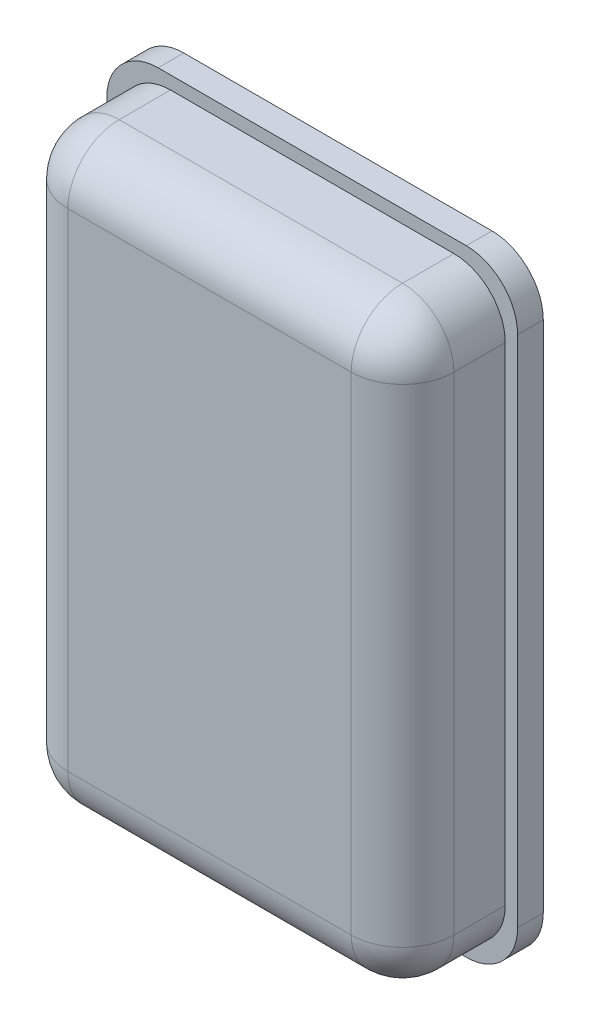
from build123d import *

# Parameters (mm, degrees)
CROQUIS1_W              = 80
CROQUIS1_H              = 120
SALIENTE_EXTRUIR1_DEPTH = 5
REDONDEO2_R             = 10
CROQUIS2_W              = 75.177590538
CROQUIS2_H              = 114.928834806
SALIENTE_EXTRUIR2_DEPTH = 20
REDONDEO1_R             = 10


with BuildPart() as part:
    # Croquis1 → Saliente-Extruir1 (new body)
    with BuildSketch(Plane.XY):
        Rectangle(CROQUIS1_W, CROQUIS1_H)
    extrude(amount=SALIENTE_EXTRUIR1_DEPTH)

    # Redondeo2
    redondeo2_edges = [part.edges().sort_by_distance(p)[0] for p in [
        (-40, 60, 2.5),
        (40, 60, 2.5),
        (40, -60, 2.5),
        (-40, -60, 2.5),
    ]]
    fillet(redondeo2_edges, radius=REDONDEO2_R)


with BuildPart() as body_2:
    # Croquis2 → Saliente-Extruir2 (new body)
    with BuildSketch(Plane.XY.offset(5)):
        Rectangle(CROQUIS2_W, CROQUIS2_H)
    extrude(amount=SALIENTE_EXTRUIR2_DEPTH)

    # Redondeo1
    redondeo1_edges = [body_2.edges().sort_by_distance(p)[0] for p in [
        (-37.588795269, 0, 25),
        (0, -57.464417403, 25),
        (37.588795269, 0, 25),
        (37.588795269, -57.464417403, 15),
        (-37.588795269, -57.464417403, 15),
        (-37.588795269, 57.464417403, 15),
        (37.588795269, 57.464417403, 15),
        (0, 57.464417403, 25),
    ]]
    fillet(redondeo1_edges, radius=REDONDEO1_R)


solid = Compound([part.part, body_2.part])
